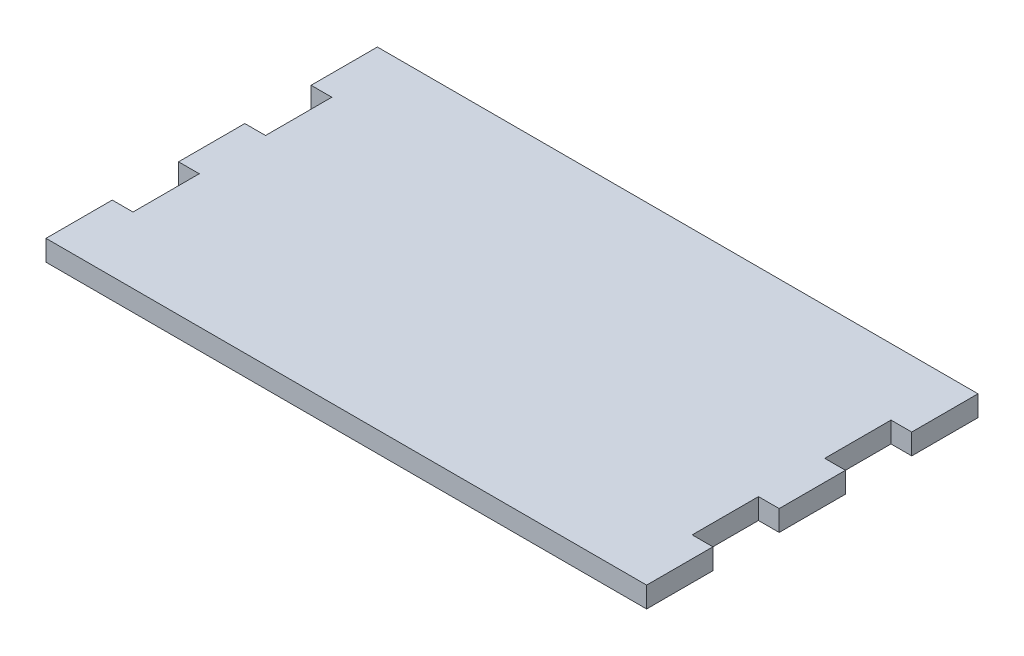
from build123d import *

# Parameters (mm, degrees)
BOSS_EXTRUDE1_DEPTH = 5


with BuildPart() as part:
    # Sketch1 → Boss-Extrude1 (new body)
    with BuildSketch(Plane(origin=(0, 0, 0), x_dir=(1, 0, 0), z_dir=(0, 1, 0))):
        Polygon((-67.5, 24), (-67.5, 8), (-72.5, 8), (-72.5, -8), (-67.5, -8), (-67.5, -24), (-72.5, -24), (-72.5, -40), (72.5, -40), (72.5, -24), (67.5, -24), (67.5, -8), (72.5, -8), (72.5, 8), (67.5, 8), (67.5, 24), (72.5, 24), (72.5, 40), (-72.5, 40), (-72.5, 24), align=None)
    extrude(amount=BOSS_EXTRUDE1_DEPTH)


solid = part.part
